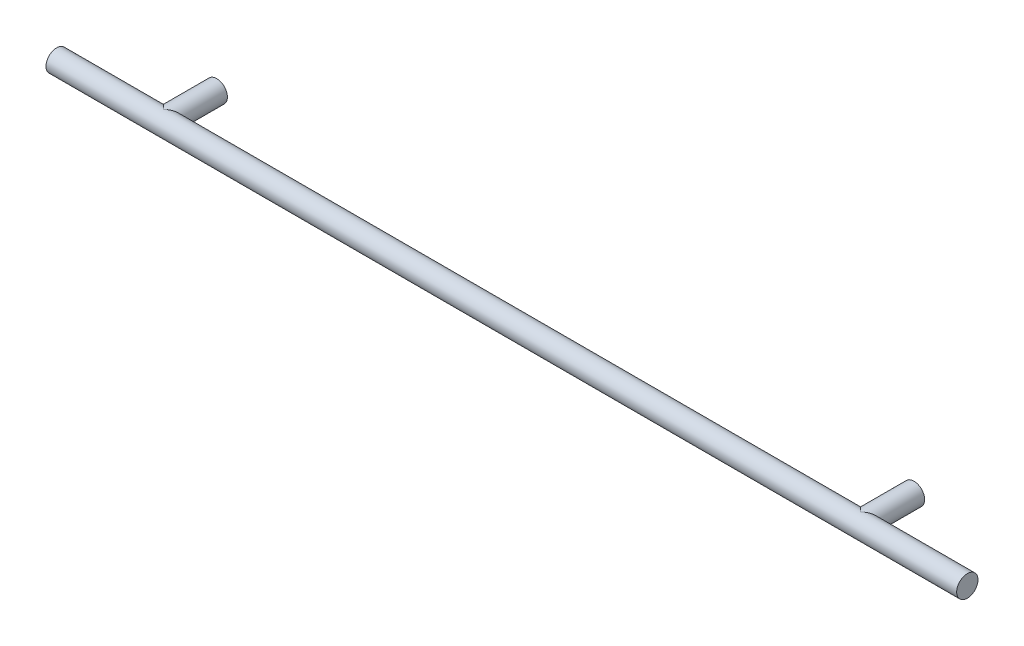
from build123d import *

# Parameters (mm, degrees)
SKETCH2_R           = 4.7625
BOSS_EXTRUDE1_DEPTH = 203.2
BOSS_EXTRUDE2_REACH = 30.575
SKETCH1_R           = 4.7625


with BuildPart() as part:
    # Sketch2 → Boss-Extrude1 (new body, symmetric)
    with BuildSketch(Plane(origin=(0, 0, 0), x_dir=(0, 0, -1), z_dir=(1, 0, 0))):
        with Locations((-23.8125, 0)):
            Circle(SKETCH2_R)
    extrude(amount=BOSS_EXTRUDE1_DEPTH, both=True)

    # Sketch1 → Boss-Extrude2 (add, up to next)
    with BuildSketch(Plane.XY, mode=Mode.PRIVATE) as boss_extrude2_sk1:
        with Locations((-155.575, 0)):
            Circle(SKETCH1_R)
    boss_extrude2_tool1 = extrude(boss_extrude2_sk1.sketch, amount=BOSS_EXTRUDE2_REACH, mode=Mode.PRIVATE) - part.part
    add(boss_extrude2_tool1.solids().sort_by_distance((-155.575, 0, 0))[0])
    # Sketch1 → Boss-Extrude2 (add, up to next)
    with BuildSketch(Plane.XY, mode=Mode.PRIVATE) as boss_extrude2_sk2:
        with Locations((155.575, 0)):
            Circle(SKETCH1_R)
    boss_extrude2_tool2 = extrude(boss_extrude2_sk2.sketch, amount=BOSS_EXTRUDE2_REACH, mode=Mode.PRIVATE) - part.part
    add(boss_extrude2_tool2.solids().sort_by_distance((155.575, 0, 0))[0])


solid = part.part
